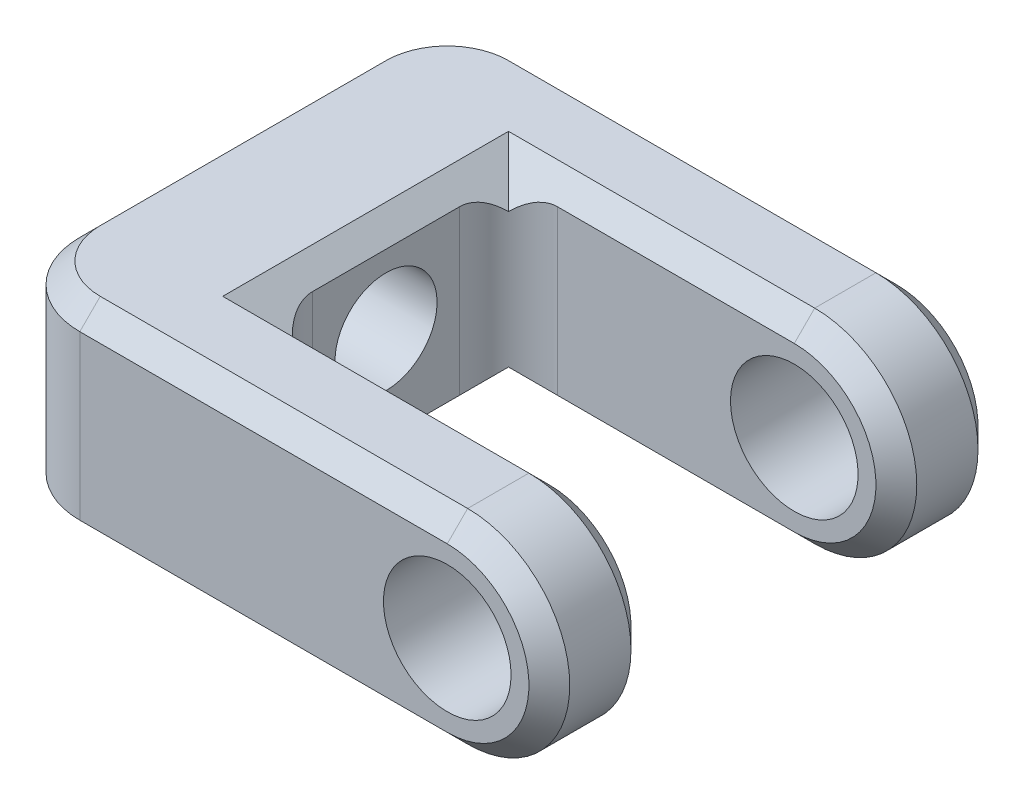
from build123d import *

# Parameters (mm, degrees)
SKETCH1_R           = 4.9609375
BOSS_EXTRUDE1_DEPTH = 34.925
SKETCH2_W           = 30.1625
SKETCH2_H           = 19.05
CUT_EXTRUDE1_DEPTH  = 16.875
SKETCH3_R           = 3.96875
CUT_EXTRUDE2_DEPTH  = 43.8625
FILLET1_R           = 6.35
CHAMFER1_SIZE       = 1.5875
FILLET2_R           = 3.81


with BuildPart() as part:
    # Sketch1 → Boss-Extrude1 (new body)
    with BuildSketch(Plane.XY):
        with BuildLine():
            Line((0, 0), (34.925, 0))
            ThreePointArc((34.925, 0), (42.8625, 7.9375), (34.925, 15.875))
            Line((34.925, 15.875), (0, 15.875))
            Line((0, 15.875), (0, 0))
        make_face()
        with Locations((34.925, 7.9375)):
            Circle(SKETCH1_R, mode=Mode.SUBTRACT)
    extrude(amount=BOSS_EXTRUDE1_DEPTH)

    # Sketch2 → Cut-Extrude1 (cut, through all)
    with BuildSketch(Plane(origin=(0, 15.875, 0), x_dir=(1, 0, 0), z_dir=(0, 1, 0))):
        with Locations((27.78125, -17.4625)):
            Rectangle(SKETCH2_W, SKETCH2_H)
    extrude(amount=-CUT_EXTRUDE1_DEPTH, mode=Mode.SUBTRACT)

    # Sketch3 → Cut-Extrude2 (cut, through all)
    with BuildSketch(Plane.ZY):
        with Locations((17.4625, 8.73125)):
            Circle(SKETCH3_R)
    extrude(amount=-CUT_EXTRUDE2_DEPTH, mode=Mode.SUBTRACT)

    # Fillet1
    fillet1_edges = [part.edges().sort_by_distance(p)[0] for p in [
        (0, 7.9375, 34.925),
        (0, 7.9375, 0),
    ]]
    fillet(fillet1_edges, radius=FILLET1_R)

    # Chamfer1
    chamfer1_edges = [part.edges().sort_by_distance(p)[0] for p in [
        (42.8625, 7.9375, 34.925),
        (20.6375, 15.875, 34.925),
        (23.8125, 15.875, 26.9875),
        (23.8125, 15.875, 7.9375),
        (12.7, 15.875, 17.4625),
        (42.8625, 7.9375, 7.9375),
        (23.8125, 0, 7.9375),
        (42.8625, 7.9375, 26.9875),
        (23.8125, 0, 26.9875),
        (12.7, 0, 17.4625),
        (20.6375, 15.875, 0),
        (0, 0, 17.4625),
        (0, 15.875, 17.4625),
        (42.8625, 7.9375, 0),
        (20.6375, 0, 34.925),
        (20.6375, 0, 0),
        (1.859871939, 0, 33.065128061),
        (1.859871939, 0, 1.859871939),
        (1.859871939, 15.875, 33.065128061),
        (1.859871939, 15.875, 1.859871939),
    ]]
    chamfer(chamfer1_edges, length=CHAMFER1_SIZE)

    # Fillet2
    fillet2_edges = [part.edges().sort_by_distance(p)[0] for p in [
        (12.7, 7.9375, 26.9875),
        (12.7, 7.9375, 7.9375),
    ]]
    fillet(fillet2_edges, radius=FILLET2_R)


solid = part.part
